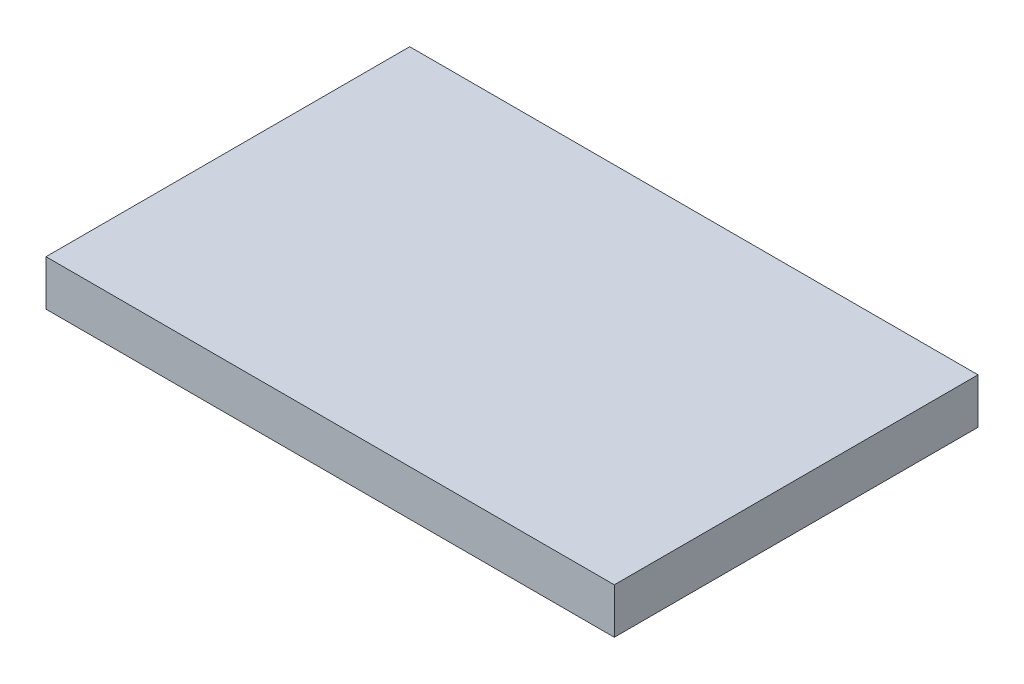
from build123d import *

# Parameters (mm, degrees)
SKETCH1_W           = 635
SKETCH1_H           = 50.8
BOSS_EXTRUDE1_DEPTH = 406.4


with BuildPart() as part:
    # Sketch1 → Boss-Extrude1 (new body)
    with BuildSketch(Plane.XY):
        with Locations((-132.5, 324.6)):
            Rectangle(SKETCH1_W, SKETCH1_H)
    extrude(amount=BOSS_EXTRUDE1_DEPTH)


solid = part.part
